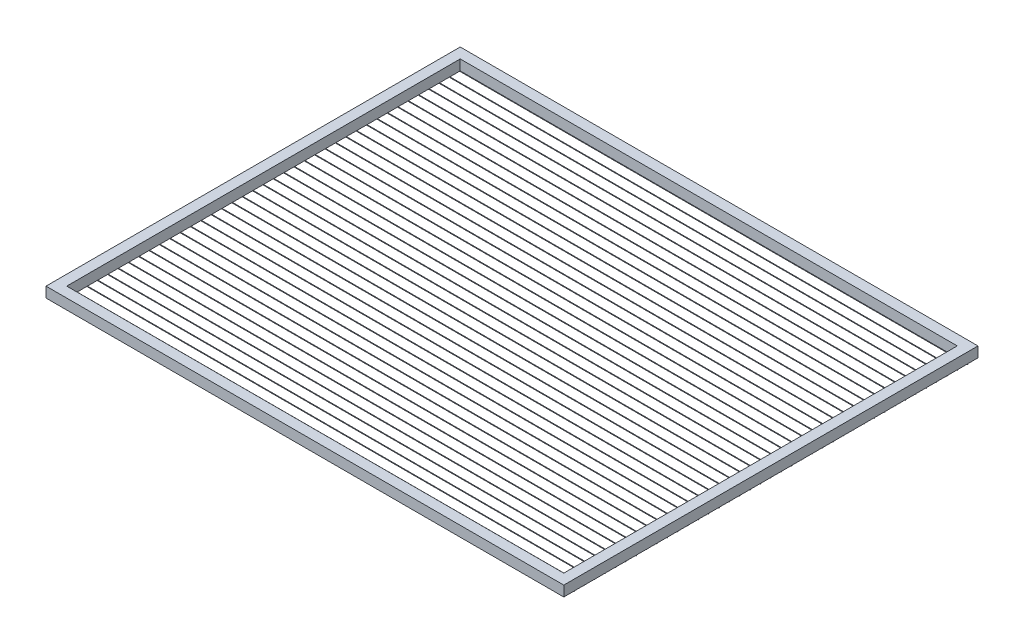
from build123d import *

# Parameters (mm, degrees)
SKETCH1_W              = 500
SKETCH1_H              = 400
SKETCH1_W_2            = 480
SKETCH1_H_2            = 380
BOSS_EXTRUDE1_DEPTH    = 10
SKETCH3_R              = 0.25
BOSS_EXTRUDE2_DEPTH    = 500
BOSS_EXTRUDE2_2_DEPTH  = 500
BOSS_EXTRUDE2_3_DEPTH  = 500
BOSS_EXTRUDE2_4_DEPTH  = 500
BOSS_EXTRUDE2_5_DEPTH  = 500
BOSS_EXTRUDE2_6_DEPTH  = 500
BOSS_EXTRUDE2_7_DEPTH  = 500
BOSS_EXTRUDE2_8_DEPTH  = 500
BOSS_EXTRUDE2_9_DEPTH  = 500
BOSS_EXTRUDE2_10_DEPTH = 500
BOSS_EXTRUDE2_11_DEPTH = 500
BOSS_EXTRUDE2_12_DEPTH = 500
BOSS_EXTRUDE2_13_DEPTH = 500
BOSS_EXTRUDE2_14_DEPTH = 500
BOSS_EXTRUDE2_15_DEPTH = 500
BOSS_EXTRUDE2_16_DEPTH = 500
BOSS_EXTRUDE2_17_DEPTH = 500
BOSS_EXTRUDE2_18_DEPTH = 500
BOSS_EXTRUDE2_19_DEPTH = 500
BOSS_EXTRUDE2_20_DEPTH = 500
BOSS_EXTRUDE2_21_DEPTH = 500
BOSS_EXTRUDE2_22_DEPTH = 500
BOSS_EXTRUDE2_23_DEPTH = 500
BOSS_EXTRUDE2_24_DEPTH = 500
BOSS_EXTRUDE2_25_DEPTH = 500
BOSS_EXTRUDE2_26_DEPTH = 500
BOSS_EXTRUDE2_27_DEPTH = 500
BOSS_EXTRUDE2_28_DEPTH = 500
BOSS_EXTRUDE2_29_DEPTH = 500
BOSS_EXTRUDE2_30_DEPTH = 500
BOSS_EXTRUDE2_31_DEPTH = 500
BOSS_EXTRUDE2_32_DEPTH = 500
BOSS_EXTRUDE2_33_DEPTH = 500
BOSS_EXTRUDE2_34_DEPTH = 500
BOSS_EXTRUDE2_35_DEPTH = 500
BOSS_EXTRUDE2_36_DEPTH = 500
BOSS_EXTRUDE2_37_DEPTH = 500
BOSS_EXTRUDE2_38_DEPTH = 500
BOSS_EXTRUDE2_39_DEPTH = 500


with BuildPart() as part:
    # Sketch1 → Boss-Extrude1 (new body)
    with BuildSketch(Plane(origin=(0, 0, 0), x_dir=(1, 0, 0), z_dir=(0, 1, 0))):
        Rectangle(SKETCH1_W, SKETCH1_H)
        Rectangle(SKETCH1_W_2, SKETCH1_H_2, mode=Mode.SUBTRACT)
    extrude(amount=BOSS_EXTRUDE1_DEPTH)


with BuildPart() as body_2:
    # Sketch3 → Boss-Extrude2 (new body)
    with BuildSketch(Plane(origin=(250, 0, 0), x_dir=(0, 0, -1), z_dir=(1, 0, 0))):
        with Locations((0, -0.25)):
            Circle(SKETCH3_R)
    extrude(amount=-BOSS_EXTRUDE2_DEPTH)


with BuildPart() as body_3:
    # Sketch3 → Boss-Extrude2 2 (new body)
    with BuildSketch(Plane(origin=(250, 0, 0), x_dir=(0, 0, -1), z_dir=(1, 0, 0))):
        with Locations((-10, -0.25)):
            Circle(SKETCH3_R)
    extrude(amount=-BOSS_EXTRUDE2_2_DEPTH)


with BuildPart() as body_4:
    # Sketch3 → Boss-Extrude2 3 (new body)
    with BuildSketch(Plane(origin=(250, 0, 0), x_dir=(0, 0, -1), z_dir=(1, 0, 0))):
        with Locations((-20, -0.25)):
            Circle(SKETCH3_R)
    extrude(amount=-BOSS_EXTRUDE2_3_DEPTH)


with BuildPart() as body_5:
    # Sketch3 → Boss-Extrude2 4 (new body)
    with BuildSketch(Plane(origin=(250, 0, 0), x_dir=(0, 0, -1), z_dir=(1, 0, 0))):
        with Locations((-30, -0.25)):
            Circle(SKETCH3_R)
    extrude(amount=-BOSS_EXTRUDE2_4_DEPTH)


with BuildPart() as body_6:
    # Sketch3 → Boss-Extrude2 5 (new body)
    with BuildSketch(Plane(origin=(250, 0, 0), x_dir=(0, 0, -1), z_dir=(1, 0, 0))):
        with Locations((-40, -0.25)):
            Circle(SKETCH3_R)
    extrude(amount=-BOSS_EXTRUDE2_5_DEPTH)


with BuildPart() as body_7:
    # Sketch3 → Boss-Extrude2 6 (new body)
    with BuildSketch(Plane(origin=(250, 0, 0), x_dir=(0, 0, -1), z_dir=(1, 0, 0))):
        with Locations((-50, -0.25)):
            Circle(SKETCH3_R)
    extrude(amount=-BOSS_EXTRUDE2_6_DEPTH)


with BuildPart() as body_8:
    # Sketch3 → Boss-Extrude2 7 (new body)
    with BuildSketch(Plane(origin=(250, 0, 0), x_dir=(0, 0, -1), z_dir=(1, 0, 0))):
        with Locations((-60, -0.25)):
            Circle(SKETCH3_R)
    extrude(amount=-BOSS_EXTRUDE2_7_DEPTH)


with BuildPart() as body_9:
    # Sketch3 → Boss-Extrude2 8 (new body)
    with BuildSketch(Plane(origin=(250, 0, 0), x_dir=(0, 0, -1), z_dir=(1, 0, 0))):
        with Locations((-70, -0.25)):
            Circle(SKETCH3_R)
    extrude(amount=-BOSS_EXTRUDE2_8_DEPTH)


with BuildPart() as body_10:
    # Sketch3 → Boss-Extrude2 9 (new body)
    with BuildSketch(Plane(origin=(250, 0, 0), x_dir=(0, 0, -1), z_dir=(1, 0, 0))):
        with Locations((-80, -0.25)):
            Circle(SKETCH3_R)
    extrude(amount=-BOSS_EXTRUDE2_9_DEPTH)


with BuildPart() as body_11:
    # Sketch3 → Boss-Extrude2 10 (new body)
    with BuildSketch(Plane(origin=(250, 0, 0), x_dir=(0, 0, -1), z_dir=(1, 0, 0))):
        with Locations((-90, -0.25)):
            Circle(SKETCH3_R)
    extrude(amount=-BOSS_EXTRUDE2_10_DEPTH)


with BuildPart() as body_12:
    # Sketch3 → Boss-Extrude2 11 (new body)
    with BuildSketch(Plane(origin=(250, 0, 0), x_dir=(0, 0, -1), z_dir=(1, 0, 0))):
        with Locations((-100, -0.25)):
            Circle(SKETCH3_R)
    extrude(amount=-BOSS_EXTRUDE2_11_DEPTH)


with BuildPart() as body_13:
    # Sketch3 → Boss-Extrude2 12 (new body)
    with BuildSketch(Plane(origin=(250, 0, 0), x_dir=(0, 0, -1), z_dir=(1, 0, 0))):
        with Locations((-110, -0.25)):
            Circle(SKETCH3_R)
    extrude(amount=-BOSS_EXTRUDE2_12_DEPTH)


with BuildPart() as body_14:
    # Sketch3 → Boss-Extrude2 13 (new body)
    with BuildSketch(Plane(origin=(250, 0, 0), x_dir=(0, 0, -1), z_dir=(1, 0, 0))):
        with Locations((-120, -0.25)):
            Circle(SKETCH3_R)
    extrude(amount=-BOSS_EXTRUDE2_13_DEPTH)


with BuildPart() as body_15:
    # Sketch3 → Boss-Extrude2 14 (new body)
    with BuildSketch(Plane(origin=(250, 0, 0), x_dir=(0, 0, -1), z_dir=(1, 0, 0))):
        with Locations((-130, -0.25)):
            Circle(SKETCH3_R)
    extrude(amount=-BOSS_EXTRUDE2_14_DEPTH)


with BuildPart() as body_16:
    # Sketch3 → Boss-Extrude2 15 (new body)
    with BuildSketch(Plane(origin=(250, 0, 0), x_dir=(0, 0, -1), z_dir=(1, 0, 0))):
        with Locations((-140, -0.25)):
            Circle(SKETCH3_R)
    extrude(amount=-BOSS_EXTRUDE2_15_DEPTH)


with BuildPart() as body_17:
    # Sketch3 → Boss-Extrude2 16 (new body)
    with BuildSketch(Plane(origin=(250, 0, 0), x_dir=(0, 0, -1), z_dir=(1, 0, 0))):
        with Locations((-150, -0.25)):
            Circle(SKETCH3_R)
    extrude(amount=-BOSS_EXTRUDE2_16_DEPTH)


with BuildPart() as body_18:
    # Sketch3 → Boss-Extrude2 17 (new body)
    with BuildSketch(Plane(origin=(250, 0, 0), x_dir=(0, 0, -1), z_dir=(1, 0, 0))):
        with Locations((-160, -0.25)):
            Circle(SKETCH3_R)
    extrude(amount=-BOSS_EXTRUDE2_17_DEPTH)


with BuildPart() as body_19:
    # Sketch3 → Boss-Extrude2 18 (new body)
    with BuildSketch(Plane(origin=(250, 0, 0), x_dir=(0, 0, -1), z_dir=(1, 0, 0))):
        with Locations((-170, -0.25)):
            Circle(SKETCH3_R)
    extrude(amount=-BOSS_EXTRUDE2_18_DEPTH)


with BuildPart() as body_20:
    # Sketch3 → Boss-Extrude2 19 (new body)
    with BuildSketch(Plane(origin=(250, 0, 0), x_dir=(0, 0, -1), z_dir=(1, 0, 0))):
        with Locations((-180, -0.25)):
            Circle(SKETCH3_R)
    extrude(amount=-BOSS_EXTRUDE2_19_DEPTH)


with BuildPart() as body_21:
    # Sketch3 → Boss-Extrude2 20 (new body)
    with BuildSketch(Plane(origin=(250, 0, 0), x_dir=(0, 0, -1), z_dir=(1, 0, 0))):
        with Locations((-190, -0.25)):
            Circle(SKETCH3_R)
    extrude(amount=-BOSS_EXTRUDE2_20_DEPTH)


with BuildPart() as body_22:
    # Sketch3 → Boss-Extrude2 21 (new body)
    with BuildSketch(Plane(origin=(250, 0, 0), x_dir=(0, 0, -1), z_dir=(1, 0, 0))):
        with Locations((10, -0.25)):
            Circle(SKETCH3_R)
    extrude(amount=-BOSS_EXTRUDE2_21_DEPTH)


with BuildPart() as body_23:
    # Sketch3 → Boss-Extrude2 22 (new body)
    with BuildSketch(Plane(origin=(250, 0, 0), x_dir=(0, 0, -1), z_dir=(1, 0, 0))):
        with Locations((20, -0.25)):
            Circle(SKETCH3_R)
    extrude(amount=-BOSS_EXTRUDE2_22_DEPTH)


with BuildPart() as body_24:
    # Sketch3 → Boss-Extrude2 23 (new body)
    with BuildSketch(Plane(origin=(250, 0, 0), x_dir=(0, 0, -1), z_dir=(1, 0, 0))):
        with Locations((30, -0.25)):
            Circle(SKETCH3_R)
    extrude(amount=-BOSS_EXTRUDE2_23_DEPTH)


with BuildPart() as body_25:
    # Sketch3 → Boss-Extrude2 24 (new body)
    with BuildSketch(Plane(origin=(250, 0, 0), x_dir=(0, 0, -1), z_dir=(1, 0, 0))):
        with Locations((40, -0.25)):
            Circle(SKETCH3_R)
    extrude(amount=-BOSS_EXTRUDE2_24_DEPTH)


with BuildPart() as body_26:
    # Sketch3 → Boss-Extrude2 25 (new body)
    with BuildSketch(Plane(origin=(250, 0, 0), x_dir=(0, 0, -1), z_dir=(1, 0, 0))):
        with Locations((50, -0.25)):
            Circle(SKETCH3_R)
    extrude(amount=-BOSS_EXTRUDE2_25_DEPTH)


with BuildPart() as body_27:
    # Sketch3 → Boss-Extrude2 26 (new body)
    with BuildSketch(Plane(origin=(250, 0, 0), x_dir=(0, 0, -1), z_dir=(1, 0, 0))):
        with Locations((60, -0.25)):
            Circle(SKETCH3_R)
    extrude(amount=-BOSS_EXTRUDE2_26_DEPTH)


with BuildPart() as body_28:
    # Sketch3 → Boss-Extrude2 27 (new body)
    with BuildSketch(Plane(origin=(250, 0, 0), x_dir=(0, 0, -1), z_dir=(1, 0, 0))):
        with Locations((70, -0.25)):
            Circle(SKETCH3_R)
    extrude(amount=-BOSS_EXTRUDE2_27_DEPTH)


with BuildPart() as body_29:
    # Sketch3 → Boss-Extrude2 28 (new body)
    with BuildSketch(Plane(origin=(250, 0, 0), x_dir=(0, 0, -1), z_dir=(1, 0, 0))):
        with Locations((80, -0.25)):
            Circle(SKETCH3_R)
    extrude(amount=-BOSS_EXTRUDE2_28_DEPTH)


with BuildPart() as body_30:
    # Sketch3 → Boss-Extrude2 29 (new body)
    with BuildSketch(Plane(origin=(250, 0, 0), x_dir=(0, 0, -1), z_dir=(1, 0, 0))):
        with Locations((90, -0.25)):
            Circle(SKETCH3_R)
    extrude(amount=-BOSS_EXTRUDE2_29_DEPTH)


with BuildPart() as body_31:
    # Sketch3 → Boss-Extrude2 30 (new body)
    with BuildSketch(Plane(origin=(250, 0, 0), x_dir=(0, 0, -1), z_dir=(1, 0, 0))):
        with Locations((100, -0.25)):
            Circle(SKETCH3_R)
    extrude(amount=-BOSS_EXTRUDE2_30_DEPTH)


with BuildPart() as body_32:
    # Sketch3 → Boss-Extrude2 31 (new body)
    with BuildSketch(Plane(origin=(250, 0, 0), x_dir=(0, 0, -1), z_dir=(1, 0, 0))):
        with Locations((110, -0.25)):
            Circle(SKETCH3_R)
    extrude(amount=-BOSS_EXTRUDE2_31_DEPTH)


with BuildPart() as body_33:
    # Sketch3 → Boss-Extrude2 32 (new body)
    with BuildSketch(Plane(origin=(250, 0, 0), x_dir=(0, 0, -1), z_dir=(1, 0, 0))):
        with Locations((120, -0.25)):
            Circle(SKETCH3_R)
    extrude(amount=-BOSS_EXTRUDE2_32_DEPTH)


with BuildPart() as body_34:
    # Sketch3 → Boss-Extrude2 33 (new body)
    with BuildSketch(Plane(origin=(250, 0, 0), x_dir=(0, 0, -1), z_dir=(1, 0, 0))):
        with Locations((130, -0.25)):
            Circle(SKETCH3_R)
    extrude(amount=-BOSS_EXTRUDE2_33_DEPTH)


with BuildPart() as body_35:
    # Sketch3 → Boss-Extrude2 34 (new body)
    with BuildSketch(Plane(origin=(250, 0, 0), x_dir=(0, 0, -1), z_dir=(1, 0, 0))):
        with Locations((140, -0.25)):
            Circle(SKETCH3_R)
    extrude(amount=-BOSS_EXTRUDE2_34_DEPTH)


with BuildPart() as body_36:
    # Sketch3 → Boss-Extrude2 35 (new body)
    with BuildSketch(Plane(origin=(250, 0, 0), x_dir=(0, 0, -1), z_dir=(1, 0, 0))):
        with Locations((150, -0.25)):
            Circle(SKETCH3_R)
    extrude(amount=-BOSS_EXTRUDE2_35_DEPTH)


with BuildPart() as body_37:
    # Sketch3 → Boss-Extrude2 36 (new body)
    with BuildSketch(Plane(origin=(250, 0, 0), x_dir=(0, 0, -1), z_dir=(1, 0, 0))):
        with Locations((160, -0.25)):
            Circle(SKETCH3_R)
    extrude(amount=-BOSS_EXTRUDE2_36_DEPTH)


with BuildPart() as body_38:
    # Sketch3 → Boss-Extrude2 37 (new body)
    with BuildSketch(Plane(origin=(250, 0, 0), x_dir=(0, 0, -1), z_dir=(1, 0, 0))):
        with Locations((170, -0.25)):
            Circle(SKETCH3_R)
    extrude(amount=-BOSS_EXTRUDE2_37_DEPTH)


with BuildPart() as body_39:
    # Sketch3 → Boss-Extrude2 38 (new body)
    with BuildSketch(Plane(origin=(250, 0, 0), x_dir=(0, 0, -1), z_dir=(1, 0, 0))):
        with Locations((180, -0.25)):
            Circle(SKETCH3_R)
    extrude(amount=-BOSS_EXTRUDE2_38_DEPTH)


with BuildPart() as body_40:
    # Sketch3 → Boss-Extrude2 39 (new body)
    with BuildSketch(Plane(origin=(250, 0, 0), x_dir=(0, 0, -1), z_dir=(1, 0, 0))):
        with Locations((190, -0.25)):
            Circle(SKETCH3_R)
    extrude(amount=-BOSS_EXTRUDE2_39_DEPTH)


solid = Compound([part.part, body_2.part, body_3.part, body_4.part, body_5.part, body_6.part, body_7.part, body_8.part, body_9.part, body_10.part, body_11.part, body_12.part, body_13.part, body_14.part, body_15.part, body_16.part, body_17.part, body_18.part, body_19.part, body_20.part, body_21.part, body_22.part, body_23.part, body_24.part, body_25.part, body_26.part, body_27.part, body_28.part, body_29.part, body_30.part, body_31.part, body_32.part, body_33.part, body_34.part, body_35.part, body_36.part, body_37.part, body_38.part, body_39.part, body_40.part])
